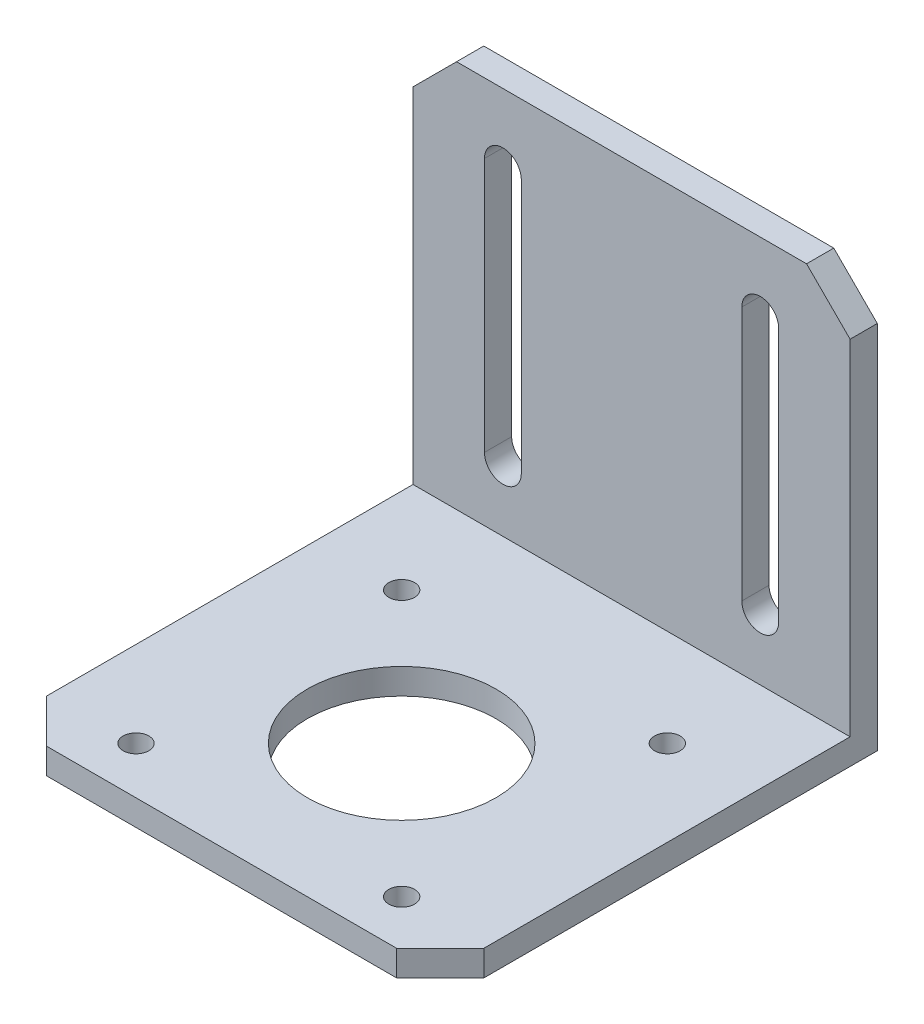
from build123d import *

# Parameters (mm, degrees)
SKETCH1_R           = 11
SKETCH1_R_2         = 1.5
BOSS_EXTRUDE1_DEPTH = 3
BOSS_EXTRUDE2_DEPTH = 3.175


with BuildPart() as part:
    # Sketch1 → Boss-Extrude1 (new body)
    with BuildSketch(Plane(origin=(0, 0, 0), x_dir=(1, 0, 0), z_dir=(0, 1, 0))):
        Polygon((20.42, -21), (-20.42, -21), (-25.5, -15.92), (-25.5, 30), (25.5, 30), (25.5, -15.92), align=None)
        Circle(SKETCH1_R, mode=Mode.SUBTRACT)
        with Locations((15.5, -15.5)):
            Circle(SKETCH1_R_2, mode=Mode.SUBTRACT)
        with Locations((-15.5, -15.5)):
            Circle(SKETCH1_R_2, mode=Mode.SUBTRACT)
        with Locations((-15.5, 15.5)):
            Circle(SKETCH1_R_2, mode=Mode.SUBTRACT)
        with Locations((15.5, 15.5)):
            Circle(SKETCH1_R_2, mode=Mode.SUBTRACT)
    extrude(amount=BOSS_EXTRUDE1_DEPTH)

    # Sketch2 → Boss-Extrude2 (add)
    with BuildSketch(Plane.XY.offset(-30)):
        Polygon((-25.5, 0), (25.5, 0), (25.5, 43.18), (20.42, 48.26), (-20.42, 48.26), (-25.5, 43.18), align=None)
        with BuildLine():
            Line((-17.165, 40.11), (-17.165, 10.41))
            ThreePointArc((-17.165, 10.41), (-15.015, 8.26), (-12.865, 10.41))
            Line((-12.865, 10.41), (-12.865, 40.11))
            ThreePointArc((-12.865, 40.11), (-15.015, 42.26), (-17.165, 40.11))
        make_face(mode=Mode.SUBTRACT)
        with BuildLine():
            Line((12.865, 40.11), (12.865, 10.41))
            ThreePointArc((12.865, 10.41), (15.015, 8.26), (17.165, 10.41))
            Line((17.165, 10.41), (17.165, 40.11))
            ThreePointArc((17.165, 40.11), (15.015, 42.26), (12.865, 40.11))
        make_face(mode=Mode.SUBTRACT)
    extrude(amount=BOSS_EXTRUDE2_DEPTH)


solid = part.part
